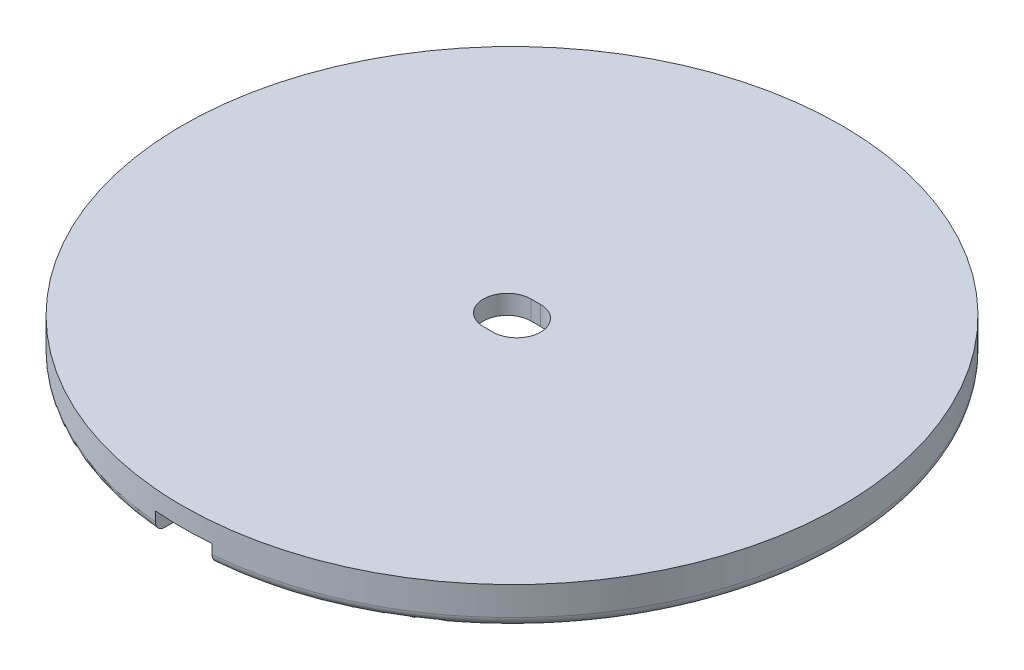
from build123d import *

# Parameters (mm, degrees)
SKETCH1_R           = 34.5
BOSS_EXTRUDE1_DEPTH = 4
CUT_EXTRUDE1_DEPTH  = 4
SKETCH3_R           = 32.5
SKETCH3_R_2         = 12.5
SKETCH3_R_3         = 7.5
CUT_EXTRUDE2_DEPTH  = 2
SKETCH4_W           = 5.931596908
SKETCH4_H           = 30.157362647
CUT_EXTRUDE3_DEPTH  = 2
FILLET1_R           = 1


with BuildPart() as part:
    # Sketch1 → Boss-Extrude1 (new body)
    with BuildSketch(Plane(origin=(0, 0, 0), x_dir=(1, 0, 0), z_dir=(0, 1, 0))):
        Circle(SKETCH1_R)
    extrude(amount=BOSS_EXTRUDE1_DEPTH)

    # Sketch2 → Cut-Extrude1 (cut)
    with BuildSketch(Plane(origin=(0, 4, 0), x_dir=(1, 0, 0), z_dir=(0, 1, 0))):
        with BuildLine():
            Line((0.5, -2.5), (-0.5, -2.5))
            ThreePointArc((-0.5, -2.5), (-3, 0), (-0.5, 2.5))
            Line((-0.5, 2.5), (0.5, 2.5))
            ThreePointArc((0.5, 2.5), (3, 0), (0.5, -2.5))
        make_face()
    extrude(amount=-CUT_EXTRUDE1_DEPTH, mode=Mode.SUBTRACT)

    # Sketch3 → Cut-Extrude2 (cut)
    with BuildSketch(Plane.XZ):
        Circle(SKETCH3_R)
        Circle(SKETCH3_R_2, mode=Mode.SUBTRACT)
        Circle(SKETCH3_R_3)
        with BuildLine():
            ThreePointArc((-0.5, -2.5), (-3, 0), (-0.5, 2.5))
            Line((-0.5, 2.5), (0.5, 2.5))
            ThreePointArc((0.5, 2.5), (3, 0), (0.5, -2.5))
            Line((0.5, -2.5), (-0.5, -2.5))
        make_face(mode=Mode.SUBTRACT)
    extrude(amount=-CUT_EXTRUDE2_DEPTH, mode=Mode.SUBTRACT)

    # Sketch4 → Cut-Extrude3 (cut)
    with BuildSketch(Plane.XZ):
        with Locations((0, 21.96737057)):
            Rectangle(SKETCH4_W, SKETCH4_H)
    extrude(amount=-CUT_EXTRUDE3_DEPTH, mode=Mode.SUBTRACT)

    # Fillet1
    fillet1_edges = [part.edges().sort_by_distance(p)[0] for p in [
        (-23.323056761, 0, -25.422136482),
    ]]
    fillet(fillet1_edges, radius=FILLET1_R)


solid = part.part
